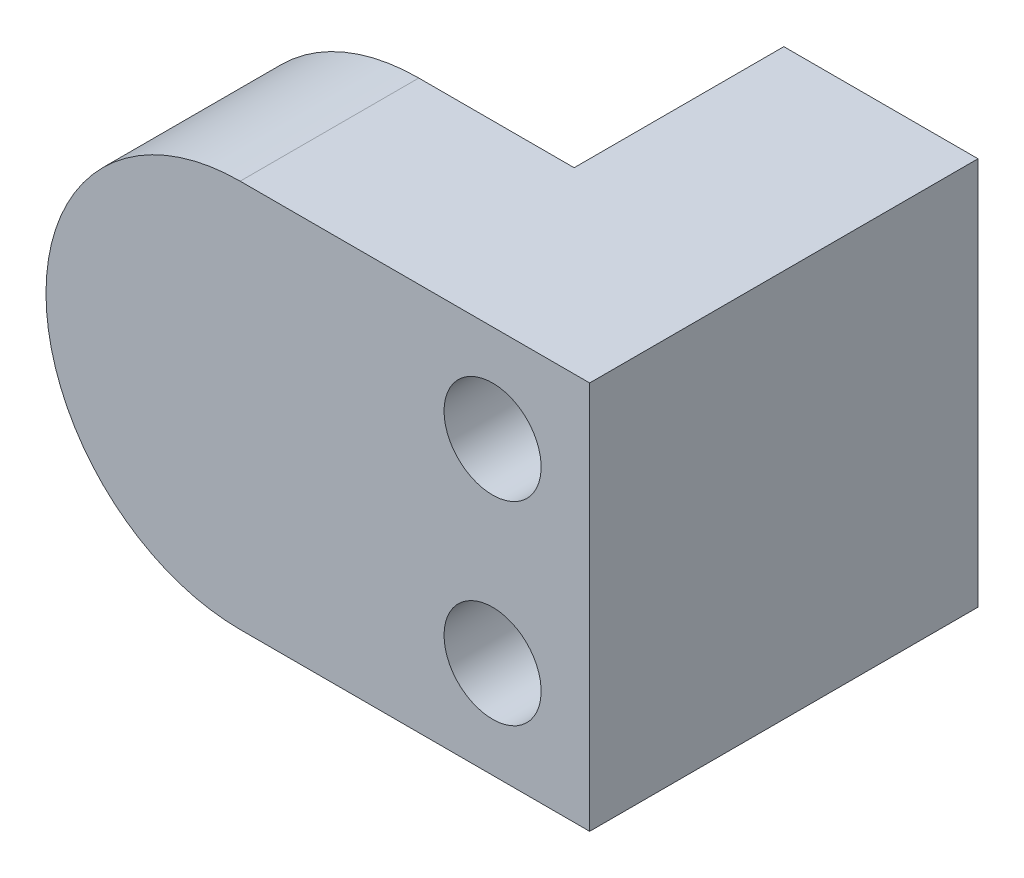
from build123d import *

# Parameters (mm, degrees)
SKETCH1_W           = 6.35
SKETCH1_H           = 12.7
BOSS_EXTRUDE1_DEPTH = 13.208
SKETCH2_W           = 6.35
SKETCH2_H           = 12.7
BOSS_EXTRUDE2_DEPTH = 5.08
SKETCH3_R           = 6.35
BOSS_EXTRUDE3_DEPTH = 6.35
SKETCH4_R           = 1.5875
CUT_EXTRUDE1_DEPTH  = 13.208
MOVE_FACE1_BY       = 0.508


with BuildPart() as part:
    # Sketch1 → Boss-Extrude1 (new body)
    with BuildSketch(Plane.XY):
        Rectangle(SKETCH1_W, SKETCH1_H)
    extrude(amount=BOSS_EXTRUDE1_DEPTH)

    # Sketch2 → Boss-Extrude2 (add)
    with BuildSketch(Plane.ZY.offset(3.175)):
        with Locations((10.033, 0)):
            Rectangle(SKETCH2_W, SKETCH2_H)
    extrude(amount=BOSS_EXTRUDE2_DEPTH)

    # Sketch3 → Boss-Extrude3 (add)
    with BuildSketch(Plane.XY.offset(13.208)):
        with Locations((-8.255, 0)):
            Circle(SKETCH3_R)
    extrude(amount=-BOSS_EXTRUDE3_DEPTH)

    # Sketch4 → Cut-Extrude1 (cut)
    with BuildSketch(Plane(origin=(0, 0, 0), x_dir=(-1, 0, 0), z_dir=(0, 0, -1))):
        with Locations((0, 3.175)):
            Circle(SKETCH4_R)
        with Locations((0, -3.175)):
            Circle(SKETCH4_R)
    extrude(amount=-CUT_EXTRUDE1_DEPTH, mode=Mode.SUBTRACT)

    # Move Face1: a face moved inward by 0.508
    extrude(part.faces().sort_by_distance((-5.513545594, 0, 13.208))[0], amount=MOVE_FACE1_BY, dir=(0, 0, -1), mode=Mode.SUBTRACT)


solid = part.part
